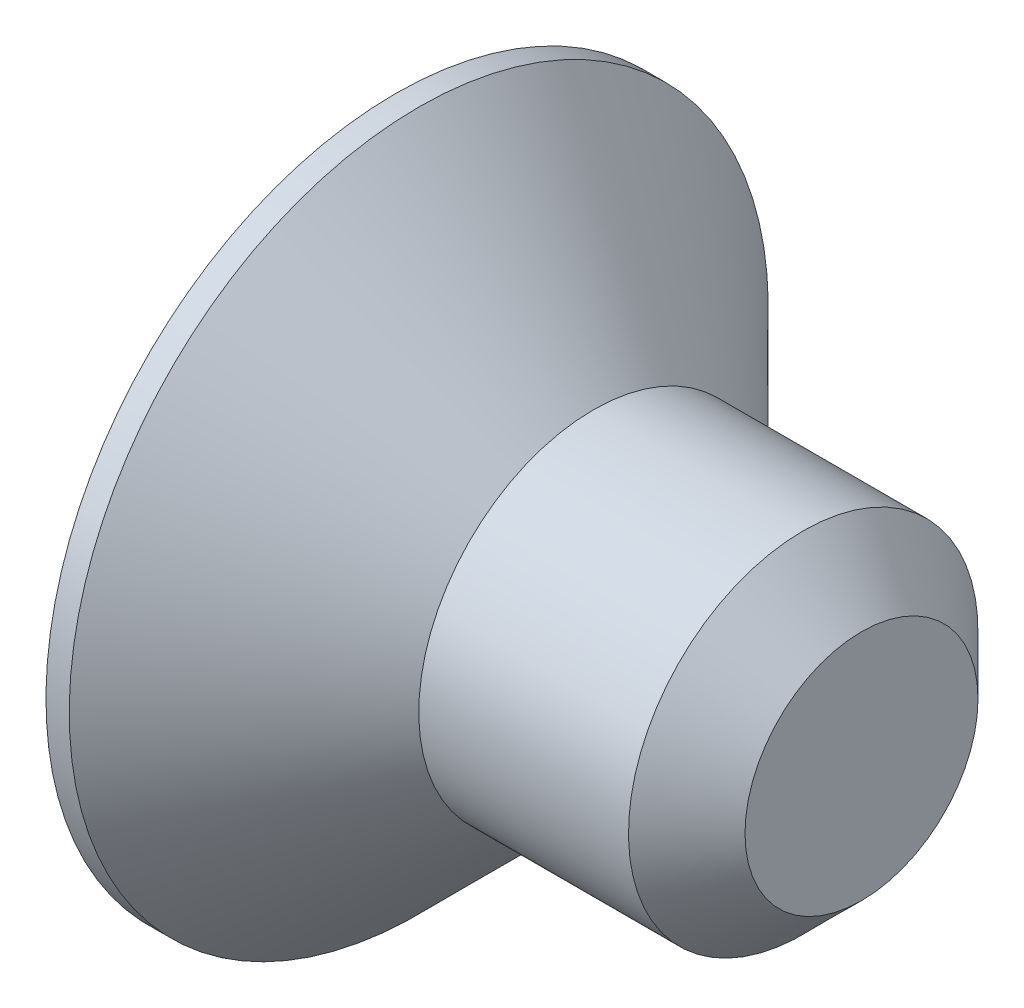
from build123d import *

# Parameters (mm, degrees)
CHANFREIN1_SIZE         = 0.5
ENL_V_MAT_EXTRU_1_DEPTH = 1.2


with BuildPart() as part:
    # Esquisse1 → Révolution1 (revolve)
    with BuildSketch(Plane.XY):
        Polygon((0, 0), (0, 3), (0.2, 3), (1.7, 1.5), (4, 1.5), (4, 0), align=None)
    revolve(axis=Axis((4, 0, 0), (-1, 0, 0)))

    # Chanfrein1
    chanfrein1_edges = [part.edges().sort_by_distance(p)[0] for p in [
        (4, -1.5, 0),
    ]]
    chamfer(chanfrein1_edges, length=CHANFREIN1_SIZE)

    # Esquisse2 → Enlèv. mat.-Extru.1 (cut)
    with BuildSketch(Plane.ZY):
        Polygon((0, 1.154700538), (-1, 0.577350269), (-1, -0.577350269), (0, -1.154700538), (1, -0.577350269), (1, 0.577350269), align=None)
    extrude(amount=-ENL_V_MAT_EXTRU_1_DEPTH, mode=Mode.SUBTRACT)


solid = part.part
